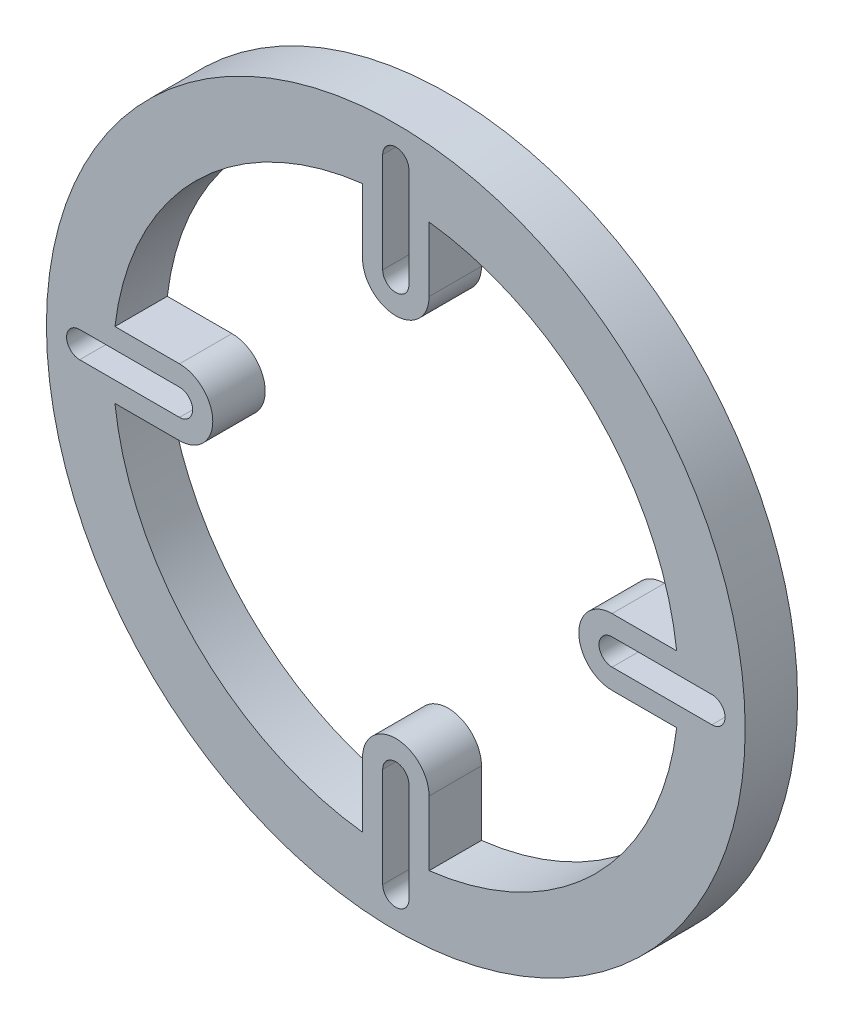
from build123d import *

# Parameters (mm, degrees)
SKETCH2_R          = 53.34
SKETCH2_R_2        = 43.18
EXTRUDE3_DEPTH     = 8
EXTRUDE4_DEPTH     = 8
EXTRUDE5_DEPTH     = 8
CUT_EXTRUDE1_DEPTH = 9
CUT_EXTRUDE2_DEPTH = 9


with BuildPart() as part:
    # Sketch2 → Extrude3 (new body)
    with BuildSketch(Plane.XY):
        Circle(SKETCH2_R)
        Circle(SKETCH2_R_2, mode=Mode.SUBTRACT)
    extrude(amount=EXTRUDE3_DEPTH)

    # Sketch3 → Extrude4 (add)
    with BuildSketch(Plane.XY.offset(8)):
        with BuildLine():
            ThreePointArc((5.08, 48.26), (0, 43.18), (-5.08, 48.26))
            Line((-5.08, 48.26), (-5.08, 33.02))
            ThreePointArc((-5.08, 33.02), (0, 27.94), (5.08, 33.02))
            Line((5.08, 33.02), (5.08, 48.26))
        make_face()
    extrude4 = extrude(amount=-EXTRUDE4_DEPTH)

    # Mirror1: Extrude4 across plane
    add(extrude4.mirror(Plane.ZX))

    # Sketch4 → Extrude5 (add)
    with BuildSketch(Plane.XY.offset(8)):
        with BuildLine():
            ThreePointArc((-48.26, 5.08), (-43.18, 0), (-48.26, -5.08))
            Line((-48.26, -5.08), (-33.02, -5.08))
            ThreePointArc((-33.02, -5.08), (-27.94, 0), (-33.02, 5.08))
            Line((-33.02, 5.08), (-48.26, 5.08))
        make_face()
    extrude5 = extrude(amount=-EXTRUDE5_DEPTH)

    # Mirror2: Extrude5 across plane
    add(extrude5.mirror(Plane(origin=(0, 0, 0), x_dir=(0, 0, 1), z_dir=(1, 0, 0))))

    # Sketch5 → Cut-Extrude1 (cut, through all)
    with BuildSketch(Plane.XY.offset(8)):
        with BuildLine():
            Line((2, 33.02), (2, 48.26))
            ThreePointArc((2, 48.26), (0, 50.26), (-2, 48.26))
            Line((-2, 48.26), (-2, 33.02))
            ThreePointArc((-2, 33.02), (0, 31.02), (2, 33.02))
        make_face()
    cut_extrude1 = extrude(amount=-CUT_EXTRUDE1_DEPTH, mode=Mode.SUBTRACT)

    # Mirror3: Cut-Extrude1 across plane
    add(cut_extrude1.mirror(Plane.ZX), mode=Mode.SUBTRACT)

    # Sketch6 → Cut-Extrude2 (cut, through all)
    with BuildSketch(Plane.XY.offset(8)):
        with BuildLine():
            Line((-33.02, 2), (-48.26, 2))
            ThreePointArc((-48.26, 2), (-50.26, 0), (-48.26, -2))
            Line((-48.26, -2), (-33.02, -2))
            ThreePointArc((-33.02, -2), (-31.02, 0), (-33.02, 2))
        make_face()
    cut_extrude2 = extrude(amount=-CUT_EXTRUDE2_DEPTH, mode=Mode.SUBTRACT)

    # Mirror4: Cut-Extrude2 across plane
    add(cut_extrude2.mirror(Plane(origin=(0, 0, 0), x_dir=(0, 0, 1), z_dir=(1, 0, 0))), mode=Mode.SUBTRACT)


solid = part.part
